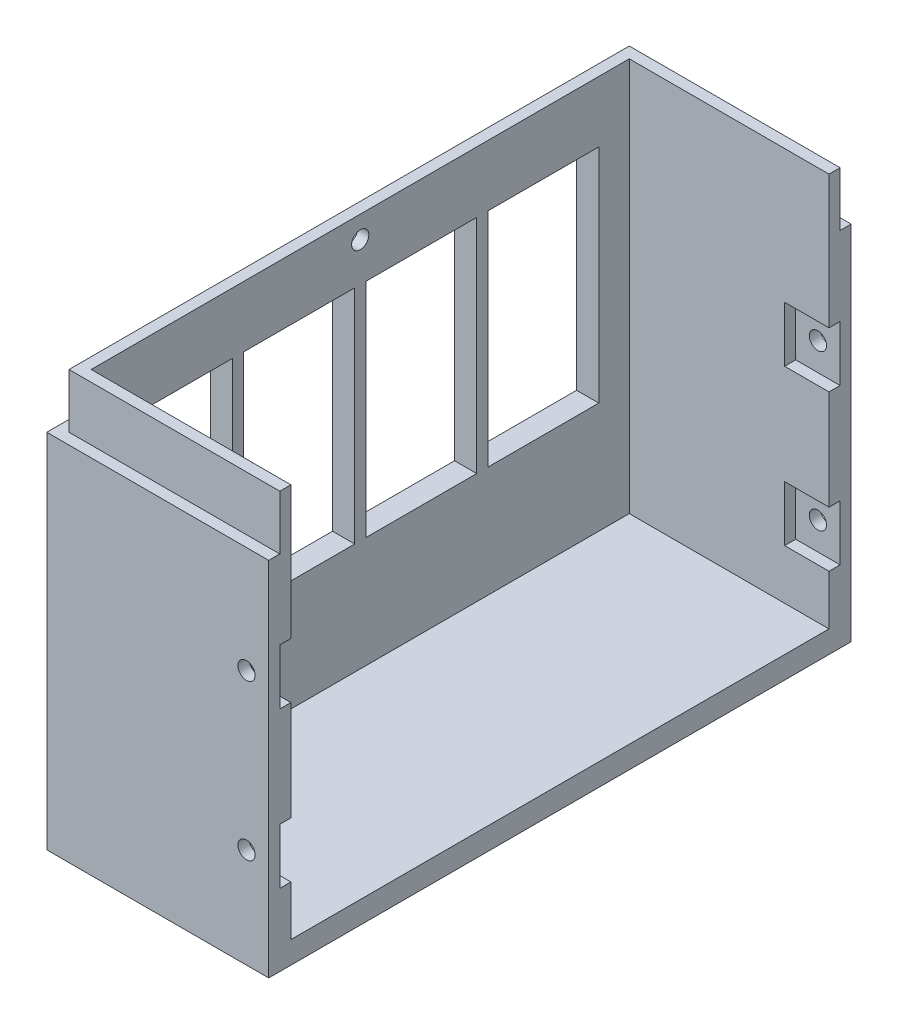
from build123d import *

# Parameters (mm, degrees)
SKETCH1_W               = 40
SKETCH1_H               = 105
BOSS_EXTRUDE3_DEPTH     = 75
SKETCH4_W               = 97
SKETCH4_H               = 71
CUT_EXTRUDE2_DEPTH      = 36
SKETCH5_W               = 40
SKETCH5_H               = 9.8
CUT_EXTRUDE3_DEPTH      = 2
SKETCH6_W               = 40
SKETCH6_H               = 9.8
CUT_EXTRUDE4_DEPTH      = 2
SKETCH7_W               = 101
SKETCH7_H               = 9.8
CUT_EXTRUDE5_DEPTH      = 2
SKETCH8_R               = 1.55
CUT_EXTRUDE6_DEPTH      = 102
CUT_EXTRUDE6_DEPTH_BACK = 5
SKETCH9_W               = 8
SKETCH9_H               = 10
CUT_EXTRUDE7_DEPTH      = 2
SKETCH10_R              = 1.55
CUT_EXTRUDE8_DEPTH      = 2
SKETCH11_W              = 8
SKETCH11_H              = 10
CUT_EXTRUDE9_DEPTH      = 2
CUT_EXTRUDE10_REACH     = 42
SKETCH12_W              = 20
SKETCH12_H              = 40


with BuildPart() as part:
    # Sketch1 → Boss-Extrude3 (new body)
    with BuildSketch(Plane(origin=(0, 0, 0), x_dir=(1, 0, 0), z_dir=(0, 1, 0))):
        Rectangle(SKETCH1_W, SKETCH1_H)
    extrude(amount=BOSS_EXTRUDE3_DEPTH)

    # Sketch4 → Cut-Extrude2 (cut)
    with BuildSketch(Plane(origin=(20, 0, 0), x_dir=(0, 0, -1), z_dir=(1, 0, 0))):
        with Locations((0, 39.5)):
            Rectangle(SKETCH4_W, SKETCH4_H)
    extrude(amount=-CUT_EXTRUDE2_DEPTH, mode=Mode.SUBTRACT)

    # Sketch5 → Cut-Extrude3 (cut)
    with BuildSketch(Plane.XY.offset(52.5)):
        with Locations((0, 70.1)):
            Rectangle(SKETCH5_W, SKETCH5_H)
    extrude(amount=-CUT_EXTRUDE3_DEPTH, mode=Mode.SUBTRACT)

    # Sketch6 → Cut-Extrude4 (cut)
    with BuildSketch(Plane(origin=(0, 0, -52.5), x_dir=(-1, 0, 0), z_dir=(0, 0, -1))):
        with Locations((0, 70.1)):
            Rectangle(SKETCH6_W, SKETCH6_H)
    extrude(amount=-CUT_EXTRUDE4_DEPTH, mode=Mode.SUBTRACT)

    # Sketch7 → Cut-Extrude5 (cut)
    with BuildSketch(Plane.ZY.offset(20)):
        with Locations((0, 70.1)):
            Rectangle(SKETCH7_W, SKETCH7_H)
    extrude(amount=-CUT_EXTRUDE5_DEPTH, mode=Mode.SUBTRACT)

    # Sketch8 → Cut-Extrude6 (cut, two sides)
    with BuildSketch(Plane(origin=(0, 0, 48.5), x_dir=(-1, 0, 0), z_dir=(0, 0, -1))) as cut_extrude6_sk:
        with Locations((-16, 18)):
            Circle(SKETCH8_R)
        with Locations((-16, 46)):
            Circle(SKETCH8_R)
    extrude(amount=CUT_EXTRUDE6_DEPTH, mode=Mode.SUBTRACT)
    extrude(cut_extrude6_sk.sketch, amount=-CUT_EXTRUDE6_DEPTH_BACK, mode=Mode.SUBTRACT)

    # Sketch9 → Cut-Extrude7 (cut)
    with BuildSketch(Plane(origin=(0, 0, 48.5), x_dir=(-1, 0, 0), z_dir=(0, 0, -1))):
        with Locations((-16, 18)):
            Rectangle(SKETCH9_W, SKETCH9_H)
        with Locations((-16, 46)):
            Rectangle(SKETCH9_W, SKETCH9_H)
    extrude(amount=-CUT_EXTRUDE7_DEPTH, mode=Mode.SUBTRACT)

    # Sketch10 → Cut-Extrude8 (cut)
    with BuildSketch(Plane.ZY.offset(18)):
        with Locations((0, 71)):
            Circle(SKETCH10_R)
    extrude(amount=-CUT_EXTRUDE8_DEPTH, mode=Mode.SUBTRACT)

    # Sketch11 → Cut-Extrude9 (cut)
    with BuildSketch(Plane.XY.offset(-48.5)):
        with Locations((16, 46)):
            Rectangle(SKETCH11_W, SKETCH11_H)
        with Locations((16, 18)):
            Rectangle(SKETCH11_W, SKETCH11_H)
    extrude(amount=-CUT_EXTRUDE9_DEPTH, mode=Mode.SUBTRACT)

    # Sketch12 → Cut-Extrude10 (cut, up to next)
    with BuildSketch(Plane.ZY.offset(20), mode=Mode.PRIVATE) as cut_extrude10_sk1:
        with Locations((-33, 44)):
            Rectangle(SKETCH12_W, SKETCH12_H)
    cut_extrude10_tool1 = extrude(cut_extrude10_sk1.sketch, amount=-CUT_EXTRUDE10_REACH, mode=Mode.PRIVATE) & part.part
    add(cut_extrude10_tool1.solids().sort_by_distance((-20, 44, -33))[0], mode=Mode.SUBTRACT)
    # Sketch12 → Cut-Extrude10 (cut, up to next)
    with BuildSketch(Plane.ZY.offset(20), mode=Mode.PRIVATE) as cut_extrude10_sk2:
        with Locations((-11, 44)):
            Rectangle(SKETCH12_W, SKETCH12_H)
    cut_extrude10_tool2 = extrude(cut_extrude10_sk2.sketch, amount=-CUT_EXTRUDE10_REACH, mode=Mode.PRIVATE) & part.part
    add(cut_extrude10_tool2.solids().sort_by_distance((-20, 44, -11))[0], mode=Mode.SUBTRACT)
    # Sketch12 → Cut-Extrude10 (cut, up to next)
    with BuildSketch(Plane.ZY.offset(20), mode=Mode.PRIVATE) as cut_extrude10_sk3:
        with Locations((11, 44)):
            Rectangle(SKETCH12_W, SKETCH12_H)
    cut_extrude10_tool3 = extrude(cut_extrude10_sk3.sketch, amount=-CUT_EXTRUDE10_REACH, mode=Mode.PRIVATE) & part.part
    add(cut_extrude10_tool3.solids().sort_by_distance((-20, 44, 11))[0], mode=Mode.SUBTRACT)
    # Sketch12 → Cut-Extrude10 (cut, up to next)
    with BuildSketch(Plane.ZY.offset(20), mode=Mode.PRIVATE) as cut_extrude10_sk4:
        with Locations((33, 44)):
            Rectangle(SKETCH12_W, SKETCH12_H)
    cut_extrude10_tool4 = extrude(cut_extrude10_sk4.sketch, amount=-CUT_EXTRUDE10_REACH, mode=Mode.PRIVATE) & part.part
    add(cut_extrude10_tool4.solids().sort_by_distance((-20, 44, 33))[0], mode=Mode.SUBTRACT)


solid = part.part
